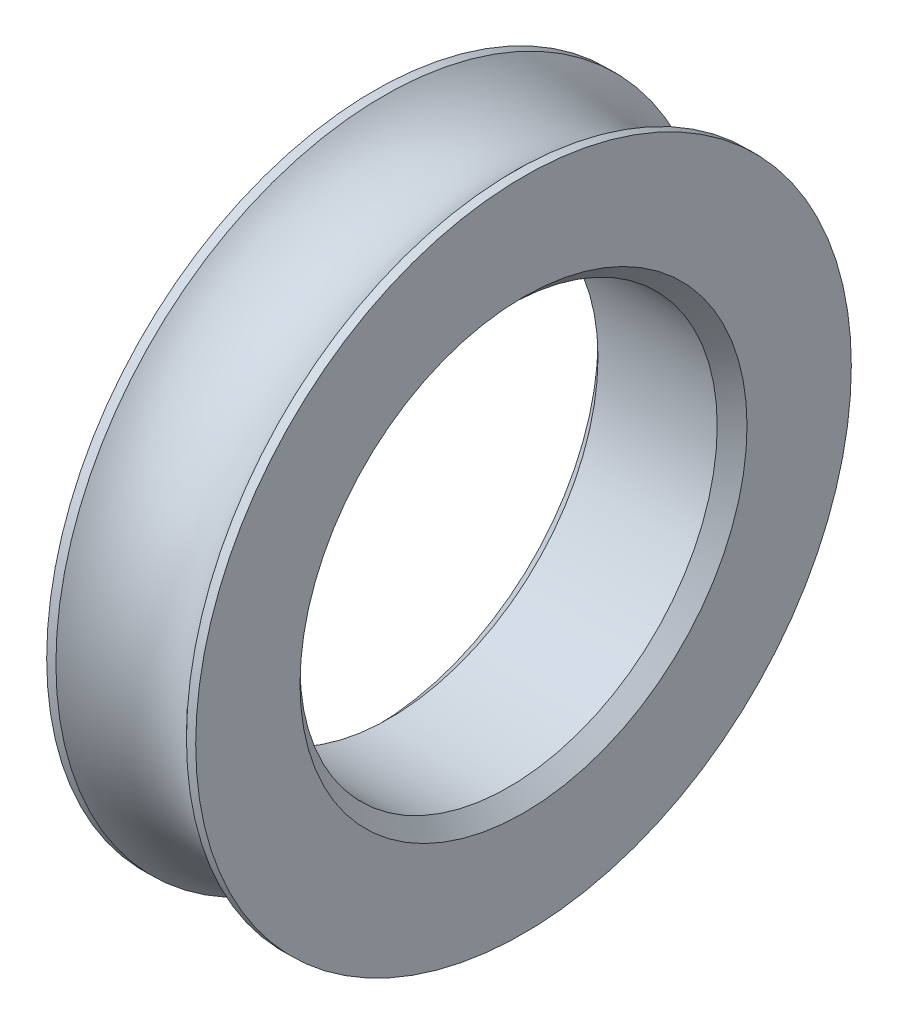
from build123d import *

# Parameters (mm, degrees)
CHAMFER1_SIZE = 0.5


with BuildPart() as part:
    # Sketch1 → Revolve1 (revolve)
    with BuildSketch(Plane.XY):
        with BuildLine():
            Line((-2.5, 11), (-2.190319611, 11))
            ThreePointArc((-2.190319611, 11), (0, 10.05), (2.190319611, 11))
            Line((2.190319611, 11), (2.5, 11))
            Line((2.5, 11), (2.5, 7))
            Line((2.5, 7), (-2.5, 7))
            Line((-2.5, 7), (-2.5, 11))
        make_face()
    revolve(axis=Axis((-15.9375, 0, 0), (1, 0, 0)))

    # Chamfer1
    chamfer1_edges = [part.edges().sort_by_distance(p)[0] for p in [
        (2.5, -7, 0),
        (-2.5, -7, 0),
    ]]
    chamfer(chamfer1_edges, length=CHAMFER1_SIZE)


solid = part.part
